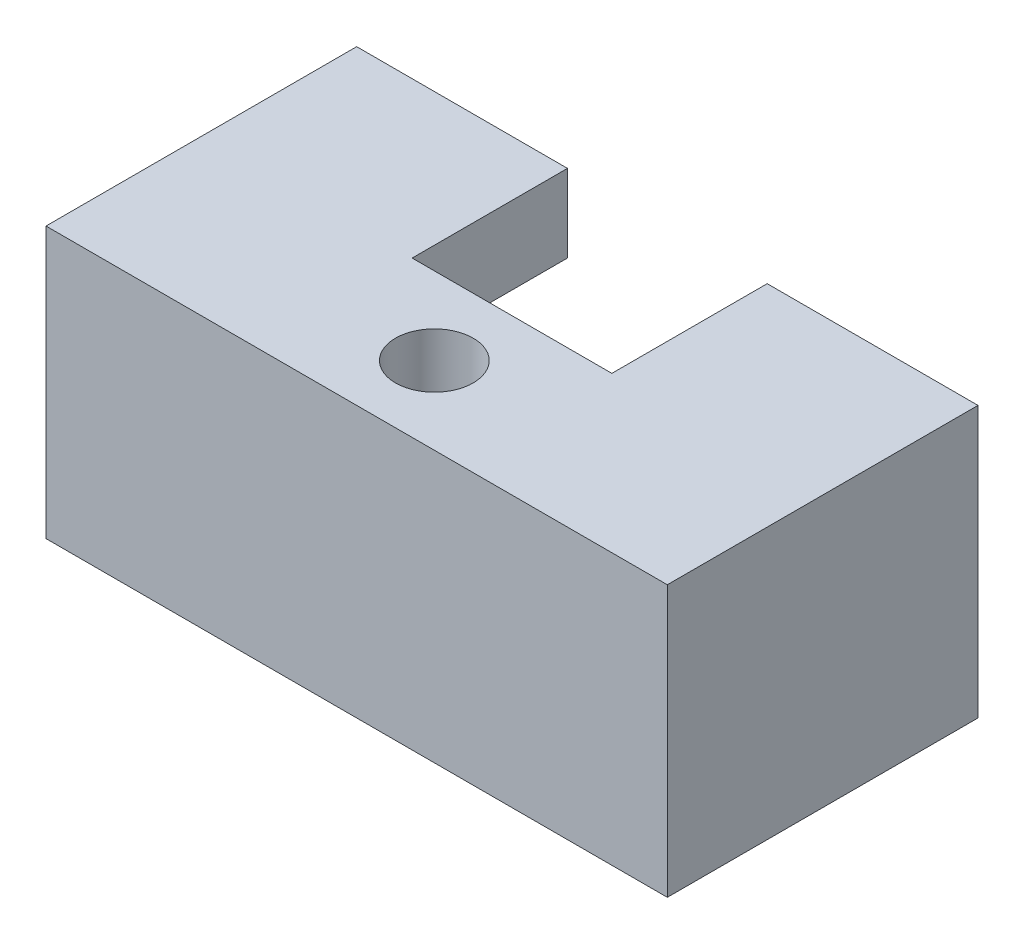
from build123d import *

# Parameters (mm, degrees)
SKETCH1_R           = 1.75
BOSS_EXTRUDE1_DEPTH = 8.7
BOSS_EXTRUDE2_START = 8.7
SKETCH1_3_R         = 1.75
BOSS_EXTRUDE2_DEPTH = 3.5


with BuildPart() as part:
    # Sketch1 → Boss-Extrude1 (new body)
    with BuildSketch(Plane(origin=(0, 0, 0), x_dir=(1, 0, 0), z_dir=(0, 1, 0))):
        Polygon((-9.25, 7), (-14, 7), (-14, -7), (14, -7), (14, 7), (9.25, 7), (9.25, 0), (4.5, 0), (-4.5, 0), (-9.25, 0), align=None)
        with Locations((0, -3.5)):
            Circle(SKETCH1_R, mode=Mode.SUBTRACT)
    extrude(amount=BOSS_EXTRUDE1_DEPTH)

    # Sketch1_3 → Boss-Extrude2 (add)
    with BuildSketch(Plane(origin=(0, 0, 0), x_dir=(1, 0, 0), z_dir=(0, 1, 0)).offset(BOSS_EXTRUDE2_START)):
        Polygon((-14, 7), (-4.5, 7), (-4.5, 0), (4.5, 0), (4.5, 7), (14, 7), (14, -7), (-14, -7), align=None)
        with Locations((0, -3.5)):
            Circle(SKETCH1_3_R, mode=Mode.SUBTRACT)
    extrude(amount=BOSS_EXTRUDE2_DEPTH)


solid = part.part
